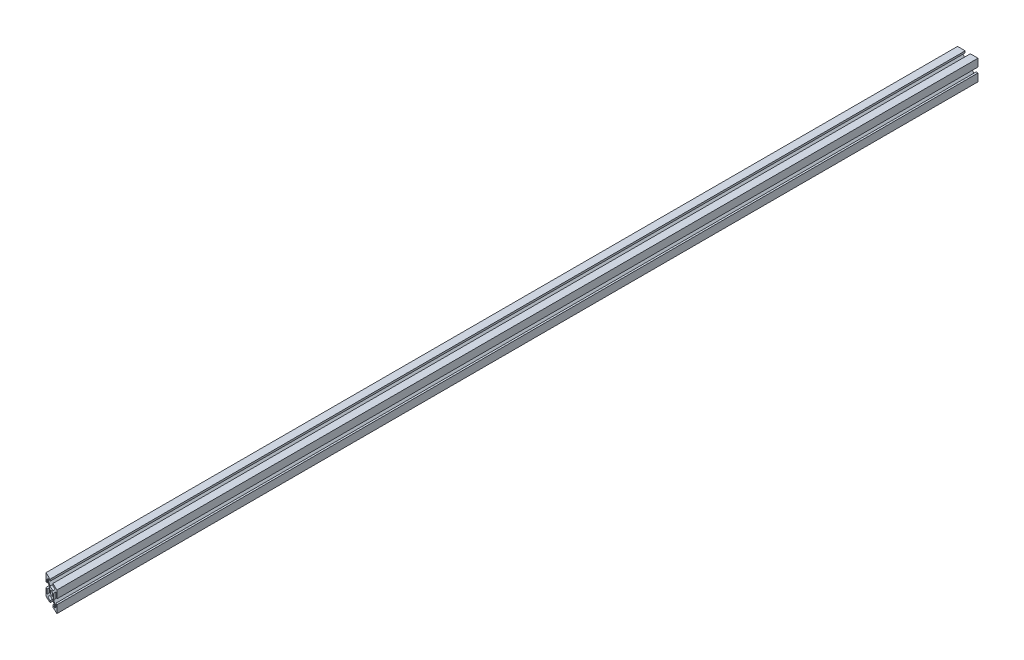
from build123d import *

# Parameters (mm, degrees)
SKETCH2_R           = 2.15
BOSS_EXTRUDE1_DEPTH = 450
CUT_EXTRUDE1_DEPTH  = 21


with BuildPart() as part:
    # Sketch2 → Boss-Extrude1 (new body, symmetric)
    with BuildSketch(Plane.XY):
        Polygon((-2.5, 10), (-2.5, 8.2), (-6.927207794, 8.2), (-2.677207794, 3.95), (2.677207794, 3.95), (6.927207794, 8.2), (2.5, 8.2), (2.5, 10), (10, 10), (10, 2.5), (8.2, 2.5), (8.2, 6.927207794), (3.95, 2.677207794), (3.95, -2.677207794), (8.2, -6.927207794), (8.2, -2.5), (10, -2.5), (10, -10), (2.5, -10), (2.5, -8.2), (6.927207794, -8.2), (2.677207794, -3.95), (-2.677207794, -3.95), (-6.927207794, -8.2), (-2.5, -8.2), (-2.5, -10), (-10, -10), (-10, -2.5), (-8.2, -2.5), (-8.2, -6.927207794), (-3.95, -2.677207794), (-3.95, 2.677207794), (-8.2, 6.927207794), (-8.2, 2.5), (-10, 2.5), (-10, 10), align=None)
        Circle(SKETCH2_R, mode=Mode.SUBTRACT)
    extrude(amount=BOSS_EXTRUDE1_DEPTH, both=True)

    # Sketch3 → Cut-Extrude1 (cut, through all)
    with BuildSketch(Plane(origin=(0, 10, 0), x_dir=(1, 0, 0), z_dir=(0, 1, 0))):
        Polygon((-10, -450), (10, -450), (-10, -440.673846837), align=None)
    extrude(amount=-CUT_EXTRUDE1_DEPTH, mode=Mode.SUBTRACT)


solid = part.part
